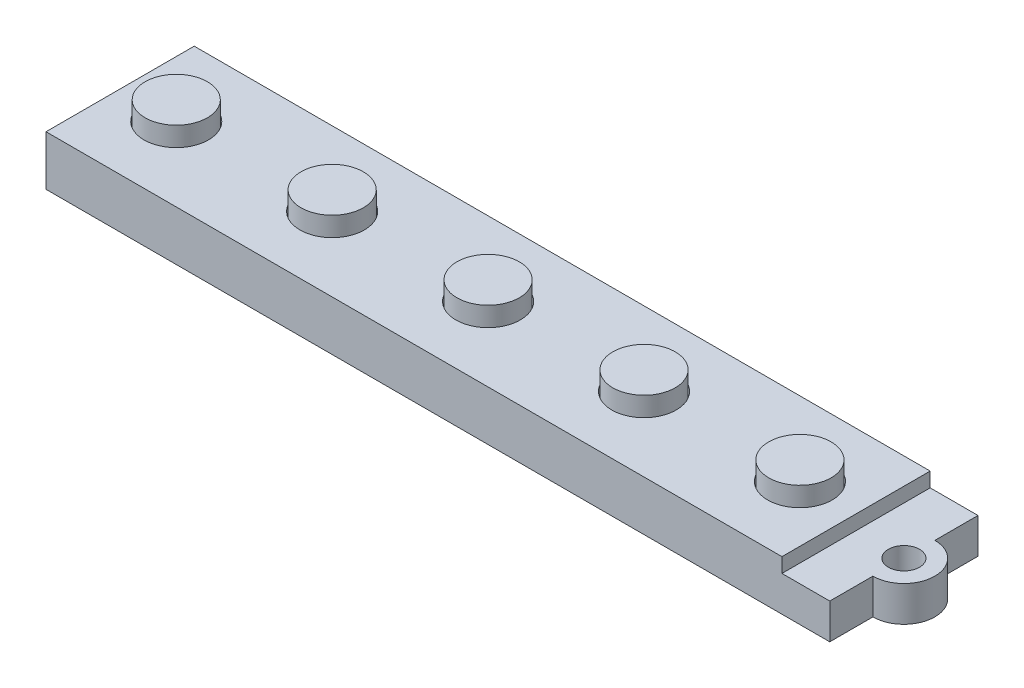
from build123d import *

# Parameters (mm, degrees)
SKETCH1_W           = 99.568
SKETCH1_H           = 18.1102
BOSS_EXTRUDE1_DEPTH = 6.096
SKETCH2_W           = 9.652
SKETCH2_H           = 18.1102
CUT_EXTRUDE1_DEPTH  = 1.778
SKETCH3_R           = 1.905
CUT_EXTRUDE2_DEPTH  = 5.318
SKETCH4_R           = 3.937
CUT_EXTRUDE3_DEPTH  = 1.27
SKETCH5_W           = 82.55
SKETCH5_H           = 12.7
BOSS_EXTRUDE2_DEPTH = 1.27
CUT_EXTRUDE4_DEPTH  = 6.588
SKETCH8_R           = 3.81
BOSS_EXTRUDE3_DEPTH = 3.556


with BuildPart() as part:
    # Sketch1 → Boss-Extrude1 (new body)
    with BuildSketch(Plane(origin=(0, 0, 0), x_dir=(1, 0, 0), z_dir=(0, 1, 0))):
        with Locations((-66.378666667, 25.894273737)):
            Rectangle(SKETCH1_W, SKETCH1_H)
    extrude(amount=BOSS_EXTRUDE1_DEPTH)

    # Sketch2 → Cut-Extrude1 (cut)
    with BuildSketch(Plane(origin=(0, 6.096, 0), x_dir=(1, 0, 0), z_dir=(0, 1, 0))):
        with Locations((-21.420666667, 25.894273737)):
            Rectangle(SKETCH2_W, SKETCH2_H)
    extrude(amount=-CUT_EXTRUDE1_DEPTH, mode=Mode.SUBTRACT)

    # Sketch3 → Cut-Extrude2 (cut, through all)
    with BuildSketch(Plane(origin=(0, 4.318, 0), x_dir=(1, 0, 0), z_dir=(0, 1, 0))):
        with Locations((-20.404666667, 25.894273737)):
            Circle(SKETCH3_R)
    extrude(amount=-CUT_EXTRUDE2_DEPTH, mode=Mode.SUBTRACT)

    # Sketch4 → Cut-Extrude3 (cut)
    with BuildSketch(Plane(origin=(0, 6.096, 0), x_dir=(1, 0, 0), z_dir=(0, 1, 0))):
        with Locations((-33.104666667, 25.894273737)):
            Circle(SKETCH4_R)
        with Locations((-52.154666667, 25.894273737)):
            Circle(SKETCH4_R)
        with Locations((-71.204666667, 25.894273737)):
            Circle(SKETCH4_R)
        with Locations((-90.254666667, 25.894273737)):
            Circle(SKETCH4_R)
        with Locations((-109.304666667, 25.894273737)):
            Circle(SKETCH4_R)
    extrude(amount=-CUT_EXTRUDE3_DEPTH, mode=Mode.SUBTRACT)

    # Sketch5 → Boss-Extrude2 (add)
    with BuildSketch(Plane.XZ):
        with Locations((-71.204666667, -25.894273737)):
            Rectangle(SKETCH5_W, SKETCH5_H)
    extrude(amount=BOSS_EXTRUDE2_DEPTH)

    # Sketch7 → Cut-Extrude4 (cut, through all)
    with BuildSketch(Plane(origin=(0, 4.318, 0), x_dir=(1, 0, 0), z_dir=(0, 1, 0))):
        with BuildLine():
            Line((-16.594666667, 34.949373737), (-20.404666667, 34.949373737))
            Line((-20.404666667, 34.949373737), (-20.404666667, 29.680045052))
            ThreePointArc((-20.404666667, 29.680045052), (-16.618895352, 25.894273737), (-20.404666667, 22.108502422))
            Line((-20.404666667, 22.108502422), (-20.404666667, 16.839173737))
            Line((-20.404666667, 16.839173737), (-16.594666667, 16.839173737))
            Line((-16.594666667, 16.839173737), (-16.594666667, 34.949373737))
        make_face()
    extrude(amount=-CUT_EXTRUDE4_DEPTH, mode=Mode.SUBTRACT)

    # Sketch8 → Boss-Extrude3 (add)
    with BuildSketch(Plane(origin=(0, 4.826, 0), x_dir=(1, 0, 0), z_dir=(0, 1, 0))):
        with Locations((-33.104666667, 25.894273737)):
            Circle(SKETCH8_R)
        with Locations((-52.154666667, 25.894273737)):
            Circle(SKETCH8_R)
        with Locations((-71.204666667, 25.894273737)):
            Circle(SKETCH8_R)
        with Locations((-90.254666667, 25.894273737)):
            Circle(SKETCH8_R)
        with Locations((-109.304666667, 25.894273737)):
            Circle(SKETCH8_R)
    extrude(amount=BOSS_EXTRUDE3_DEPTH)


solid = part.part
